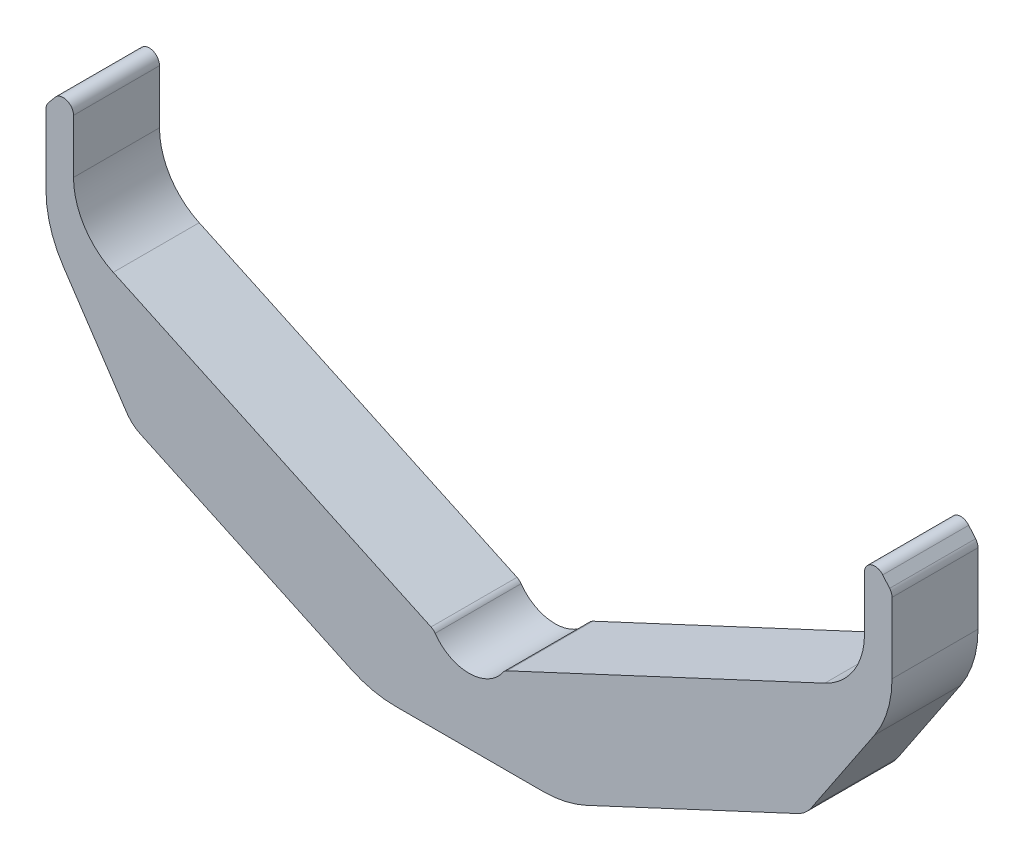
from build123d import *

# Parameters (mm, degrees)
BASE_EXTRUDE_DEPTH     = 25
M10_GEVINDHULLER_D     = 8.5
M10_GEVINDHULLER_DEPTH = 19
M10_GEVINDHULLER_TIP   = 2.553657631


with BuildPart() as part:
    # Sketch1 → Base-Extrude (new body)
    with BuildSketch(Plane.XY):
        with BuildLine():
            Line((-11.04340479, 5.149624226), (-103.452365235, 48.240630163))
            ThreePointArc((-103.452365235, 48.240630163), (-111.867828916, 55.620793737), (-115, 66.366785904))
            Line((-115, 66.366785904), (-115, 82))
            ThreePointArc((-115, 82), (-116.97393957, 84.819077862), (-120.298133329, 83.928362829))
            Line((-120.298133329, 83.928362829), (-122.298133329, 81.544855644))
            ThreePointArc((-122.298133329, 81.544855644), (-122.819077862, 80.642553245), (-123, 79.616492815))
            Line((-123, 79.616492815), (-123, 59.102819238))
            ThreePointArc((-123, 59.102819238), (-121.707567052, 50.39215945), (-117.941627071, 42.432029243))
            Line((-117.941627071, 42.432029243), (-99.553694394, 14.921337813))
            ThreePointArc((-99.553694394, 14.921337813), (-97.750312833, 12.887914315), (-95.466001321, 11.41518994))
            Line((-95.466001321, 11.41518994), (-34.123617057, -17.189233611))
            ThreePointArc((-34.123617057, -17.189233611), (-27.938257623, -19.288880214), (-21.445069205, -20))
            Line((-21.445069205, -20), (21.445069205, -20))
            ThreePointArc((21.445069205, -20), (27.938257623, -19.288880214), (34.123617057, -17.189233611))
            Line((34.123617057, -17.189233611), (95.466001321, 11.41518994))
            ThreePointArc((95.466001321, 11.41518994), (97.750312833, 12.887914315), (99.553694394, 14.921337813))
            Line((99.553694394, 14.921337813), (117.941627071, 42.432029243))
            ThreePointArc((117.941627071, 42.432029243), (121.707567052, 50.39215945), (123, 59.102819238))
            Line((123, 59.102819238), (123, 79.616492815))
            ThreePointArc((123, 79.616492815), (122.819077862, 80.642553245), (122.298133329, 81.544855644))
            Line((122.298133329, 81.544855644), (120.298133329, 83.928362829))
            ThreePointArc((120.298133329, 83.928362829), (116.97393957, 84.819077862), (115, 82))
            Line((115, 82), (115, 66.366785904))
            ThreePointArc((115, 66.366785904), (111.867828916, 55.620793737), (103.452365235, 48.240630163))
            Line((103.452365235, 48.240630163), (11.04340479, 5.149624226))
            ThreePointArc((11.04340479, 5.149624226), (10.379689702, 4.726139346), (9.84900766, 4.144560692))
            ThreePointArc((9.84900766, 4.144560692), (0, -1), (-9.84900766, 4.144560692))
            ThreePointArc((-9.84900766, 4.144560692), (-10.379689702, 4.726139346), (-11.04340479, 5.149624226))
        make_face()
    extrude(amount=BASE_EXTRUDE_DEPTH)

    # M10 gevindhuller
    with Locations(Plane(origin=(0, 0, 0), x_dir=(-1, 0, 0), z_dir=(0, 0, -1))):
        with Locations((-40, 3.205015461), (-62.657694676, 13.770472004), (-85.315389352, 24.335928548), (85.315389352, 24.335928548), (62.657694676, 13.770472004), (40, 3.205015461)):
            Hole(M10_GEVINDHULLER_D / 2, depth=M10_GEVINDHULLER_DEPTH)
            with Locations((0, 0, -(M10_GEVINDHULLER_DEPTH + M10_GEVINDHULLER_TIP / 2))):  # 118° drill point
                Cone(0, M10_GEVINDHULLER_D / 2, M10_GEVINDHULLER_TIP, mode=Mode.SUBTRACT)


solid = part.part
